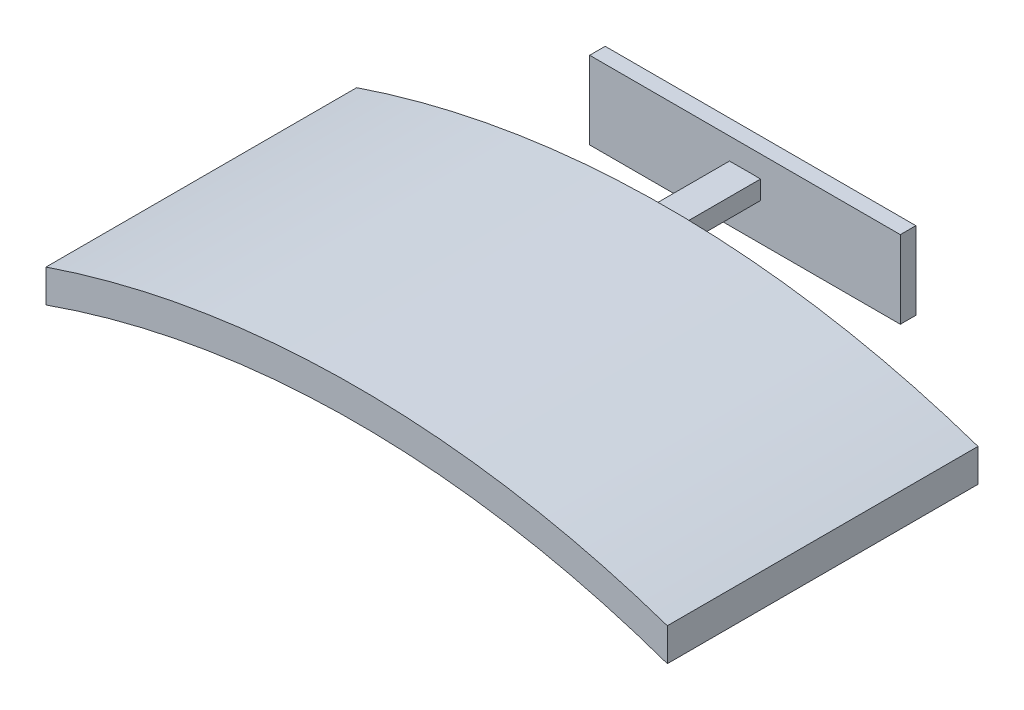
from build123d import *

# Parameters (mm, degrees)
BOSS_EXTRUDE1_DEPTH = 200
CUT_EXTRUDE1_START  = -2
CUT_EXTRUDE1_DEPTH  = 196
BOSS_EXTRUDE3_DEPTH = 50
SKETCH6_W           = 200
SKETCH6_H           = 50
BOSS_EXTRUDE4_DEPTH = 10


with BuildPart() as part:
    # Sketch1 → Boss-Extrude1 (new body)
    with BuildSketch(Plane.XY):
        with BuildLine():
            Line((0, 0), (0, 21.170605096))
            ThreePointArc((0, 21.170605096), (200, 54.314575051), (400, 21.170605096))
            Line((400, 21.170605096), (400, 0))
            ThreePointArc((400, 0), (200, 34.314575051), (0, 0))
        make_face()
    extrude(amount=BOSS_EXTRUDE1_DEPTH)

    # Sketch3 → Cut-Extrude1 (cut)
    with BuildSketch(Plane.XY.offset(200).offset(CUT_EXTRUDE1_START)):
        with BuildLine():
            Line((2, 1.762370006), (2, 0.703134257))
            ThreePointArc((2, 0.703134257), (200, 34.314575051), (398, 0.703134257))
            Line((398, 0.703134257), (398, 1.762370006))
            ThreePointArc((398, 1.762370006), (200, 35.314575051), (2, 1.762370006))
        make_face()
    extrude(amount=-CUT_EXTRUDE1_DEPTH, mode=Mode.SUBTRACT)

    # Sketch5 → Boss-Extrude3 (add)
    with BuildSketch(Plane(origin=(0, 0, 0), x_dir=(-1, 0, 0), z_dir=(0, 0, -1))):
        with BuildLine():
            Line((-210, 50.233400871), (-210, 38.23178792))
            ThreePointArc((-210, 38.23178792), (-200, 38.314575051), (-190, 38.23178792))
            Line((-190, 38.23178792), (-190, 50.233400871))
            ThreePointArc((-190, 50.233400871), (-200, 50.314575051), (-210, 50.233400871))
        make_face()
    extrude(amount=BOSS_EXTRUDE3_DEPTH)

    # Sketch6 → Boss-Extrude4 (add)
    with BuildSketch(Plane(origin=(0, 0, -50), x_dir=(-1, 0, 0), z_dir=(0, 0, -1))):
        with Locations((-200, 39.232594396)):
            Rectangle(SKETCH6_W, SKETCH6_H)
    extrude(amount=BOSS_EXTRUDE4_DEPTH)


solid = part.part
